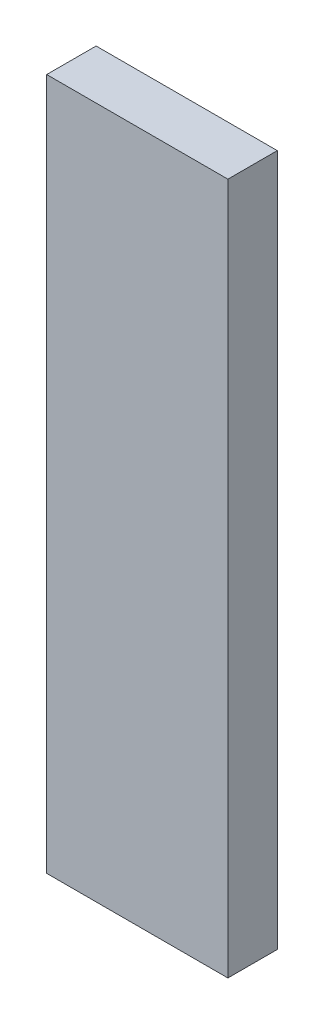
from build123d import *

# Parameters (mm, degrees)
SKETCH1_W           = 139.7
SKETCH1_H           = 38.1
BOSS_EXTRUDE1_DEPTH = 533.4


with BuildPart() as part:
    # Sketch1 → Boss-Extrude1 (new body)
    with BuildSketch(Plane(origin=(0, 0, 0), x_dir=(1, 0, 0), z_dir=(0, 1, 0))):
        Rectangle(SKETCH1_W, SKETCH1_H)
    extrude(amount=BOSS_EXTRUDE1_DEPTH)


solid = part.part
